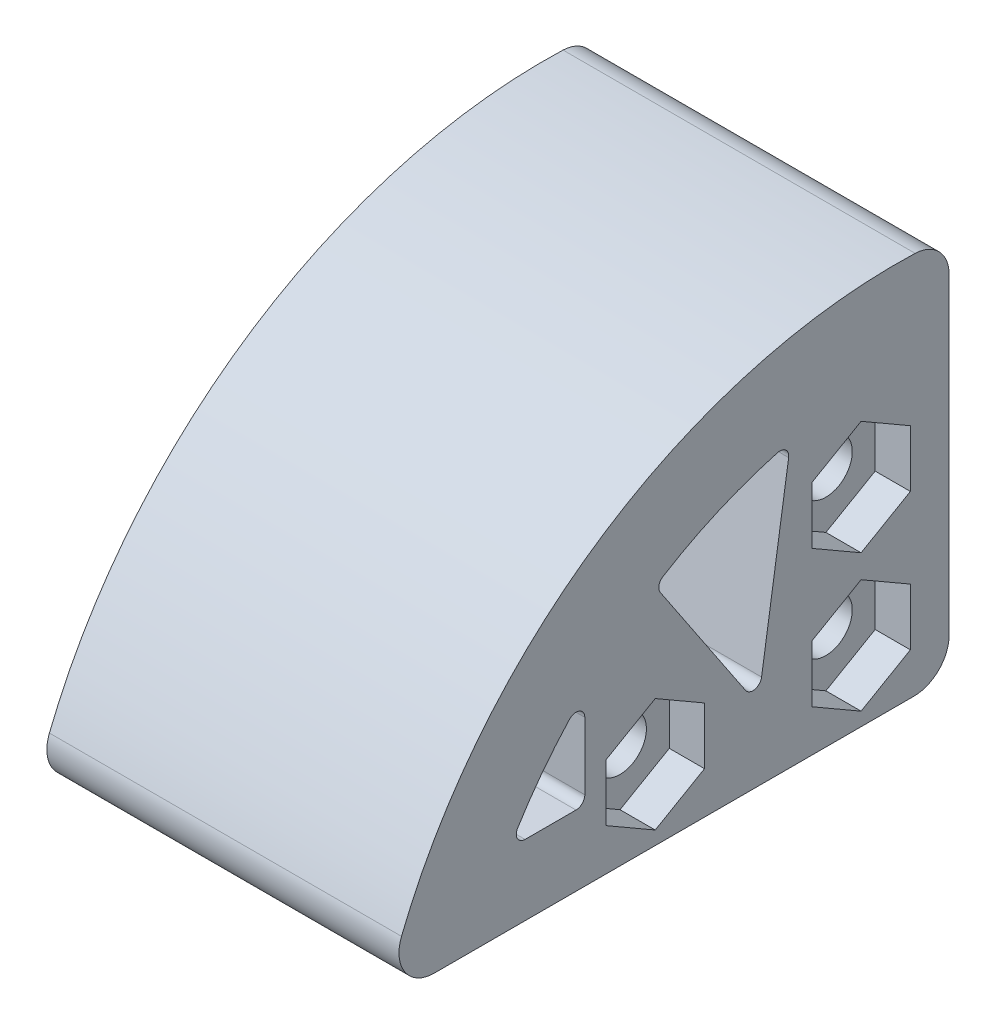
from build123d import *

# Parameters (mm, degrees)
SKETCH1_R           = 1.5
BOSS_EXTRUDE1_DEPTH = 20
CUT_EXTRUDE1_DEPTH  = 2
CUT_EXTRUDE2_START  = 20
CUT_EXTRUDE2_DEPTH  = 2


with BuildPart() as part:
    # Sketch1 → Boss-Extrude1 (new body)
    with BuildSketch(Plane(origin=(0, 0, 0), x_dir=(0, 0, -1), z_dir=(1, 0, 0))):
        with BuildLine():
            Line((-24.25, -4), (3, -4))
            ThreePointArc((3, -4), (4.414213562, -3.414213562), (5, -2))
            Line((5, -2), (5, 15.754424432))
            ThreePointArc((5, 15.754424432), (4.439006977, 17.143402085), (3.070741081, 17.753172966))
            ThreePointArc((3.070741081, 17.753172966), (-14.52537265, 12.863616062), (-26.106953382, -1.257218647))
            ThreePointArc((-26.106953382, -1.257218647), (-25.906134461, -3.121257619), (-24.25, -4))
        make_face()
        with Locations((0, 7.792107243)):
            Circle(SKETCH1_R, mode=Mode.SUBTRACT)
        Circle(SKETCH1_R, mode=Mode.SUBTRACT)
        with Locations((-11.694197133, 0)):
            Circle(SKETCH1_R, mode=Mode.SUBTRACT)
        with BuildLine():
            Line((-16.194197133, 0), (-19.086908103, 0))
            ThreePointArc((-19.086908103, 0), (-19.523483355, 0.256274644), (-19.512525938, 0.762391804))
            ThreePointArc((-19.512525938, 0.762391804), (-18.131084667, 2.778063971), (-16.561428533, 4.650894419))
            ThreePointArc((-16.561428533, 4.650894419), (-16.012010004, 4.777196244), (-15.694197133, 4.311569945))
            Line((-15.694197133, 4.311569945), (-15.694197133, 0.5))
            ThreePointArc((-15.694197133, 0.5), (-15.840643743, 0.146446609), (-16.194197133, 0))
        make_face(mode=Mode.SUBTRACT)
        with BuildLine():
            Line((-11.408525011, 8.313239357), (-6.562071453, 1.068743928))
            ThreePointArc((-6.562071453, 1.068743928), (-6.037987222, 0.85867559), (-5.652264441, 1.2709994))
            Line((-5.652264441, 1.2709994), (-4.115149007, 11.298363901))
            ThreePointArc((-4.115149007, 11.298363901), (-4.277279765, 11.747905828), (-4.742779484, 11.855999947))
            ThreePointArc((-4.742779484, 11.855999947), (-8.099246212, 10.666463574), (-11.255194335, 9.016961489))
            ThreePointArc((-11.255194335, 9.016961489), (-11.481482966, 8.697701132), (-11.408525011, 8.313239357))
        make_face(mode=Mode.SUBTRACT)
    extrude(amount=BOSS_EXTRUDE1_DEPTH)

    # Sketch2 → Cut-Extrude1 (cut)
    with BuildSketch(Plane(origin=(0, 0, 0), x_dir=(0, 0, -1), z_dir=(1, 0, 0))):
        Polygon((-11.694197133, -3.233161507), (-8.894197133, -1.616580754), (-8.894197133, 1.616580754), (-11.694197133, 3.233161507), (-14.494197133, 1.616580754), (-14.494197133, -1.616580754), align=None)
        Polygon((0, -3.233161507), (2.8, -1.616580754), (2.8, 1.616580754), (0, 3.233161507), (-2.8, 1.616580754), (-2.8, -1.616580754), align=None)
        Polygon((0, 4.558945735), (2.8, 6.175526489), (2.8, 9.408687997), (0, 11.02526875), (-2.8, 9.408687997), (-2.8, 6.175526489), align=None)
    extrude(amount=CUT_EXTRUDE1_DEPTH, mode=Mode.SUBTRACT)

    # Sketch2_2 → Cut-Extrude2 (cut)
    with BuildSketch(Plane(origin=(0, 0, 0), x_dir=(0, 0, -1), z_dir=(1, 0, 0)).offset(CUT_EXTRUDE2_START)):
        Polygon((-11.694197133, -3.233161507), (-8.894197133, -1.616580754), (-8.894197133, 1.616580754), (-11.694197133, 3.233161507), (-14.494197133, 1.616580754), (-14.494197133, -1.616580754), align=None)
        Polygon((0, -3.233161507), (2.8, -1.616580754), (2.8, 1.616580754), (0, 3.233161507), (-2.8, 1.616580754), (-2.8, -1.616580754), align=None)
        Polygon((0, 4.558945735), (2.8, 6.175526489), (2.8, 9.408687997), (0, 11.02526875), (-2.8, 9.408687997), (-2.8, 6.175526489), align=None)
    extrude(amount=-CUT_EXTRUDE2_DEPTH, mode=Mode.SUBTRACT)


solid = part.part
